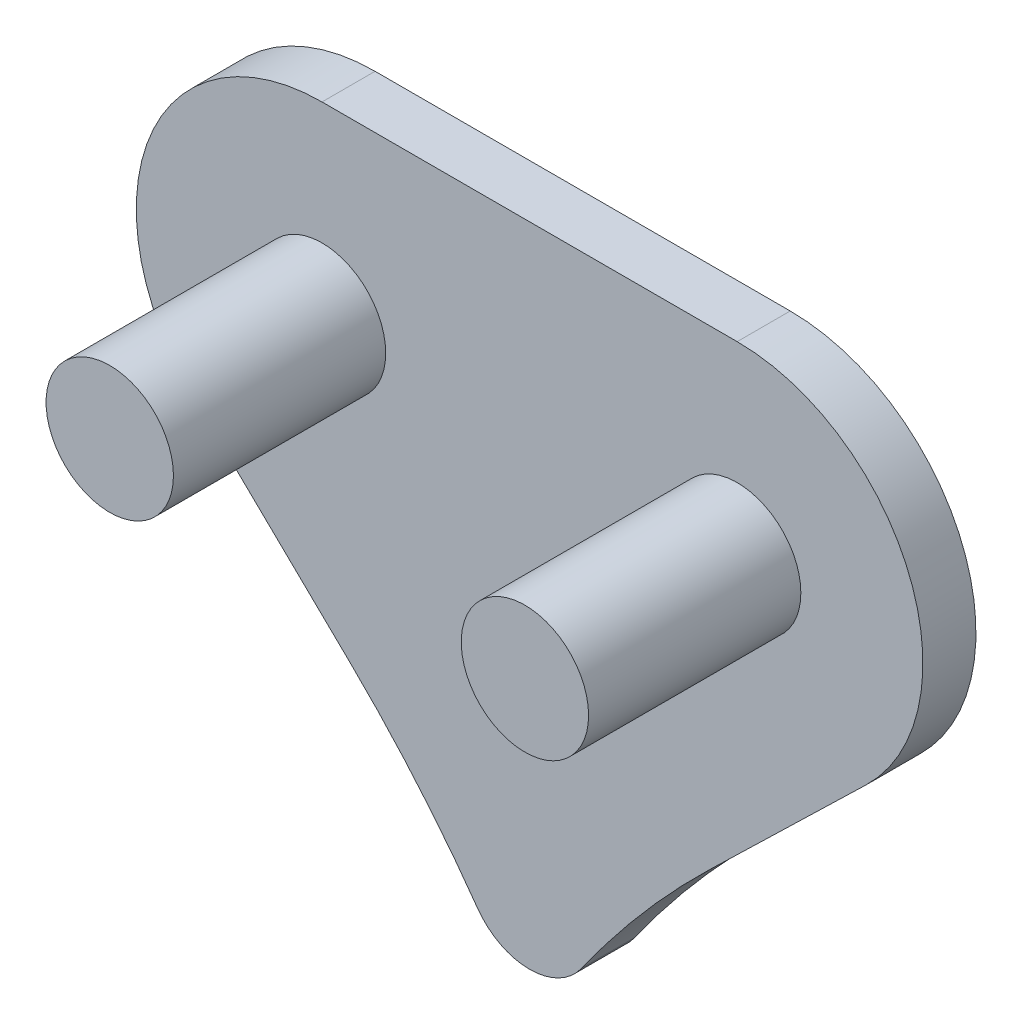
from build123d import *

# Parameters (mm, degrees)
SKETCH2_R                = 0.6
BOSS_EXTRUDE1_DEPTH      = 0.5
SKETCH3_R                = 0.6
BOSS_EXTRUDE2_DEPTH      = 2
BOSS_EXTRUDE2_DEPTH_BACK = 0.5


with BuildPart() as part:
    # Sketch2 → Boss-Extrude1 (new body)
    with BuildSketch(Plane.XY):
        with BuildLine():
            Line((-1.395963948, 1.75), (2.515834251, 1.75))
            ThreePointArc((2.515834251, 1.75), (4.137889568, 0.656838298), (3.733466312, -1.256929657))
            Line((3.733466312, -1.256929657), (2.257187702, -2.687052781))
            ThreePointArc((2.257187702, -2.687052781), (1.620755288, -3.363652659), (1.049849305, -4.096387243))
            ThreePointArc((1.049849305, -4.096387243), (0.559935151, -4.35), (0.070020998, -4.096387243))
            ThreePointArc((0.070020998, -4.096387243), (-0.500884985, -3.363652659), (-1.137317399, -2.687052781))
            Line((-1.137317399, -2.687052781), (-2.61359601, -1.256929657))
            ThreePointArc((-2.61359601, -1.256929657), (-3.018019265, 0.656838298), (-1.395963948, 1.75))
        make_face()
        with Locations((-1.395963948, 0)):
            Circle(SKETCH2_R, mode=Mode.SUBTRACT)
        with Locations((2.515834251, 0)):
            Circle(SKETCH2_R, mode=Mode.SUBTRACT)
    extrude(amount=BOSS_EXTRUDE1_DEPTH)

    # Sketch3 → Boss-Extrude2 (add, two sides)
    with BuildSketch(Plane.XY.offset(0.5)) as boss_extrude2_sk:
        with Locations((-1.395963948, 0)):
            Circle(SKETCH3_R)
        with Locations((2.515834251, 0)):
            Circle(SKETCH3_R)
    extrude(amount=BOSS_EXTRUDE2_DEPTH)
    extrude(boss_extrude2_sk.sketch, amount=-BOSS_EXTRUDE2_DEPTH_BACK)


solid = part.part
